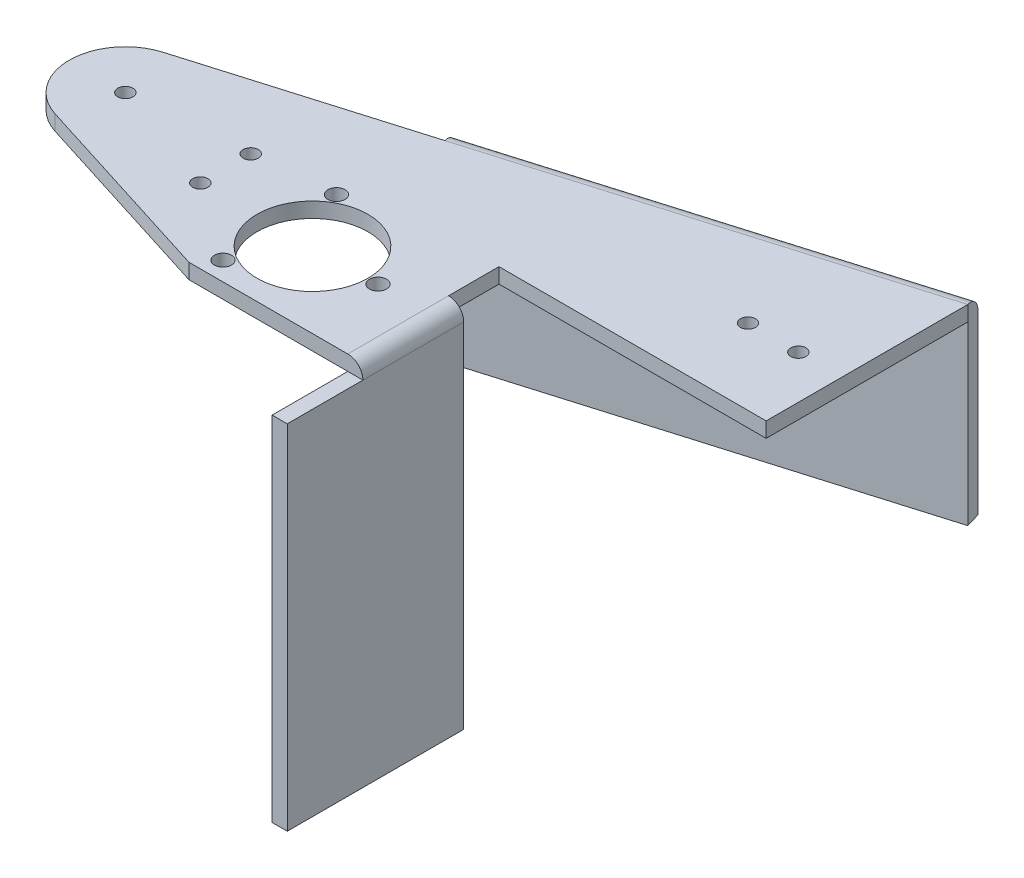
from build123d import *

# Parameters (mm, degrees)
ESQUISSE3_R        = 1.5
ESQUISSE3_R_2      = 11
ESQUISSE3_R_3      = 1.7
BOSS_EXTRU_3_DEPTH = 3
ESQUISSE6_W        = 3
ESQUISSE6_H        = 35
BOSS_EXTRU_4_DEPTH = 70
BOSS_EXTRU_5_DEPTH = 35
CONG_1_R           = 3


with BuildPart() as part:
    # Esquisse3 → Boss.-Extru.3 (new body)
    with BuildSketch(Plane.XZ):
        with BuildLine():
            Line((-464.844143116, -40.359876935), (-411.844143116, -40.359876935))
            Line((-411.844143116, -40.359876935), (-411.844143116, -80.359876935))
            Line((-411.844143116, -80.359876935), (-412.696301805, -83.236302767))
            Line((-412.696301805, -83.236302767), (-492.696301805, -59.535815029))
            Line((-492.696301805, -59.535815029), (-491.844143116, -56.659389197))
            Line((-491.844143116, -56.659389197), (-534.975651854, -43.881416773))
            ThreePointArc((-534.975651854, -43.881416773), (-542.943725497, -33.306292776), (-535.160059098, -22.594711075))
            Line((-535.160059098, -22.594711075), (-496.344143116, -10.359876935))
            Line((-496.344143116, -10.359876935), (-461.844143116, -10.359876935))
            Line((-461.844143116, -10.359876935), (-461.844143116, -30.359876935))
            Line((-461.844143116, -30.359876935), (-464.844143116, -30.359876935))
            Line((-464.844143116, -30.359876935), (-464.844143116, -40.359876935))
        make_face()
        with Locations((-531.814143116, -33.209876935)):
            Circle(ESQUISSE3_R, mode=Mode.SUBTRACT)
        with Locations((-508.844143116, -35.113476935)):
            Circle(ESQUISSE3_R, mode=Mode.SUBTRACT)
        with Locations((-508.844143116, -25.113476935)):
            Circle(ESQUISSE3_R, mode=Mode.SUBTRACT)
        with Locations((-486.844143116, -25.359876935)):
            Circle(ESQUISSE3_R_2, mode=Mode.SUBTRACT)
        with Locations((-473.844143116, -25.359876935)):
            Circle(ESQUISSE3_R_3, mode=Mode.SUBTRACT)
        with Locations((-493.344143116, -36.618207185)):
            Circle(ESQUISSE3_R_3, mode=Mode.SUBTRACT)
        with Locations((-493.344143116, -14.101546686)):
            Circle(ESQUISSE3_R_3, mode=Mode.SUBTRACT)
        with Locations((-420.455543116, -55.359876935)):
            Circle(ESQUISSE3_R, mode=Mode.SUBTRACT)
        with Locations((-430.455543116, -55.359876935)):
            Circle(ESQUISSE3_R, mode=Mode.SUBTRACT)
    extrude(amount=BOSS_EXTRU_3_DEPTH)

    # Esquisse6 → Boss.-Extru.4 (add)
    with BuildSketch(Plane.XZ.offset(3)):
        with Locations((-463.344143116, -12.859876935)):
            Rectangle(ESQUISSE6_W, ESQUISSE6_H)
    extrude(amount=BOSS_EXTRU_4_DEPTH)

    # Esquisse9 → Boss.-Extru.5 (add)
    with BuildSketch(Plane.XZ.offset(3)):
        Polygon((-492.696301805, -59.535815029), (-412.696301805, -83.236302767), (-411.844143116, -80.359876935), (-491.844143116, -56.659389197), align=None)
    extrude(amount=BOSS_EXTRU_5_DEPTH)

    # Congé1
    cong_1_edges = [part.edges().sort_by_distance(p)[0] for p in [
        (-452.696301805, 0, -71.386058898),
        (-461.844143116, 0, -20.359876935),
    ]]
    fillet(cong_1_edges, radius=CONG_1_R)


solid = part.part
